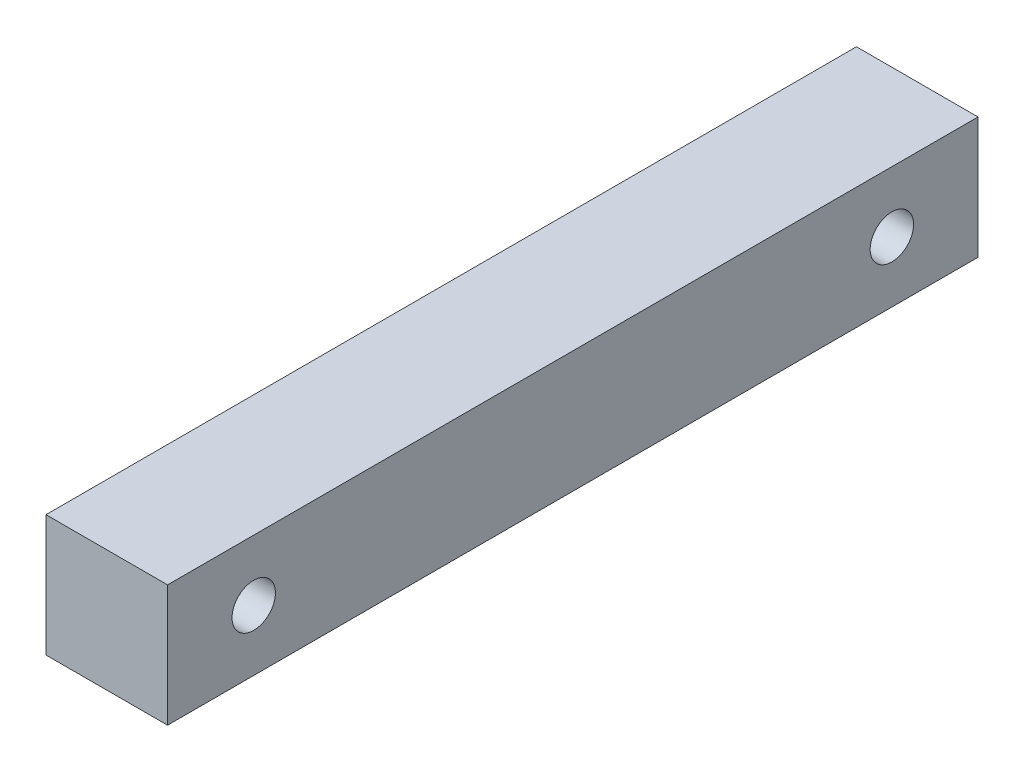
from build123d import *

# Parameters (mm, degrees)
ESBO_O1_W                = 19.05
ESBO_O1_H                = 19.05
RESSALTO_EXTRUS_O1_DEPTH = 63.5
FURO_ROSCADO_DE_M81_D    = 6.8


with BuildPart() as part:
    # Esboço1 → Ressalto-extrusão1 (new body, symmetric)
    with BuildSketch(Plane.XY):
        Rectangle(ESBO_O1_W, ESBO_O1_H)
    extrude(amount=RESSALTO_EXTRUS_O1_DEPTH, both=True)

    # Furo roscado de M81 (through all)
    with Locations(Plane(origin=(9.525, 0, 0), x_dir=(0, 0, -1), z_dir=(1, 0, 0))):
        with Locations((-50, 0), (50, 0)):
            Hole(FURO_ROSCADO_DE_M81_D / 2)


solid = part.part
